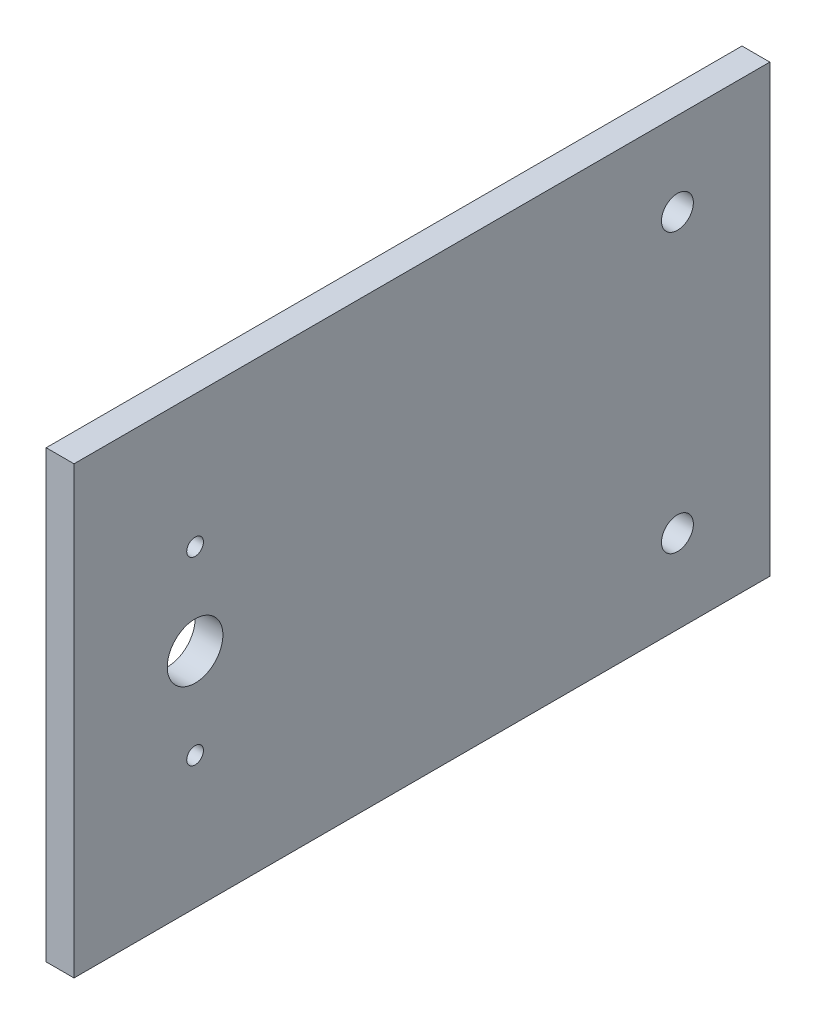
from build123d import *

# Parameters (mm, degrees)
SKETCH1_W           = 80
SKETCH1_H           = 125
SKETCH1_R           = 5
SKETCH1_R_2         = 1.5
SKETCH1_R_3         = 2.866822522
BOSS_EXTRUDE1_DEPTH = 5


with BuildPart() as part:
    # Sketch1 → Boss-Extrude1 (new body)
    with BuildSketch(Plane.YZ):
        Rectangle(SKETCH1_W, SKETCH1_H)
        with Locations((0, 40.75)):
            Circle(SKETCH1_R, mode=Mode.SUBTRACT)
        with Locations((-16.22, 40.75)):
            Circle(SKETCH1_R_2, mode=Mode.SUBTRACT)
        with Locations((16.22, 40.75)):
            Circle(SKETCH1_R_2, mode=Mode.SUBTRACT)
        with Locations((-25, -45.9)):
            Circle(SKETCH1_R_3, mode=Mode.SUBTRACT)
        with Locations((25, -45.9)):
            Circle(SKETCH1_R_3, mode=Mode.SUBTRACT)
    extrude(amount=BOSS_EXTRUDE1_DEPTH)


solid = part.part
